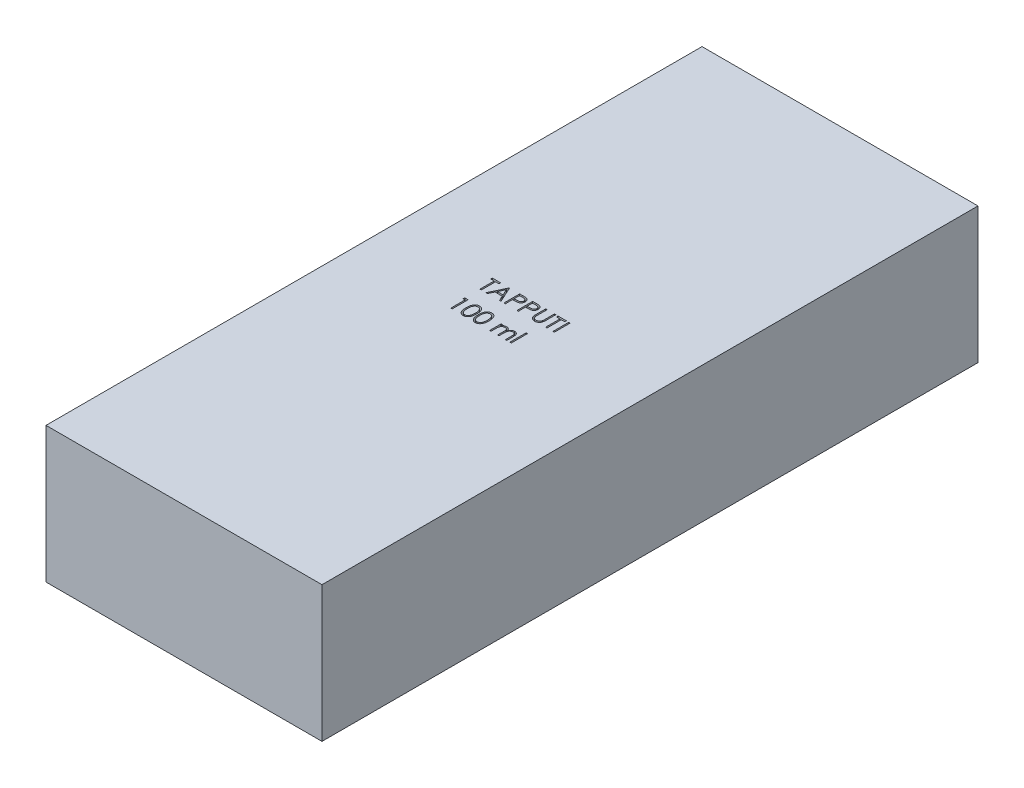
from build123d import *

# Parameters (mm, degrees)
SKETCH1_W           = 61
SKETCH1_H           = 145
BOSS_EXTRUDE1_DEPTH = 30
SKETCH2_W           = 0.314102564
SKETCH2_H           = 3.5
SKETCH2_H_2         = 3.58974359
CUT_EXTRUDE1_DEPTH  = 10


with BuildPart() as part:
    # Sketch1 → Boss-Extrude1 (new body)
    with BuildSketch(Plane(origin=(0, 0, 0), x_dir=(1, 0, 0), z_dir=(0, 1, 0))):
        Rectangle(SKETCH1_W, SKETCH1_H)
    extrude(amount=-BOSS_EXTRUDE1_DEPTH)

    # Sketch2 → Cut-Extrude1 (cut)
    with BuildSketch(Plane(origin=(0, 0, 0), x_dir=(1, 0, 0), z_dir=(0, 1, 0))):
        Polygon((-9.37530333, 4.660408726), (-9.37530333, 5.019383085), (-7.53555974, 5.019383085), (-7.53555974, 4.660408726), (-8.298380253, 4.660408726), (-8.298380253, 1.519383085), (-8.612482817, 1.519383085), (-8.612482817, 4.660408726), align=None)
        Polygon((-5.561200766, 5.019383085), (-3.94581615, 1.519383085), (-4.287262464, 1.519383085), (-4.804690349, 2.641177956), (-6.391328971, 2.641177956), (-6.923480413, 1.519383085), (-7.266328971, 1.519383085), (-5.60607256, 5.019383085), align=None)
        Polygon((-5.587142272, 4.337191578), (-6.220956374, 3.000152315), (-4.970155092, 3.000152315), align=None, mode=Mode.SUBTRACT)
        with BuildLine():
            Line((-3.317611022, 5.019383085), (-2.631212785, 5.019383085))
            add(Edge.make_bspline(
                [(-2.631212785, 5.019383085), (-2.584001879, 5.019331188), (-2.493543686, 5.019231753), (-2.36382863, 5.016217007), (-2.246018898, 5.012190315), (-2.140368518, 5.006608422), (-2.046552419, 5.000011831), (-1.96499512, 4.990759792), (-1.895055564, 4.981099497), (-1.853149114, 4.97127809), (-1.834037304, 4.96679895)],
                knots=[0, 0, 0, 0, 0.000141628, 0.000271366, 0.00038923, 0.000495248, 0.00058876, 0.000671296, 0.000741499, 0.00080036, 0.00080036, 0.00080036, 0.00080036], degree=3))
            add(Edge.make_bspline(
                [(-1.834037304, 4.96679895), (-1.80984377, 4.960177), (-1.762026793, 4.947089138), (-1.69312575, 4.920875415), (-1.627571904, 4.88979325), (-1.565140346, 4.85436931), (-1.506598263, 4.813083746), (-1.451072222, 4.767610128), (-1.399052242, 4.716898559), (-1.35083085, 4.66151782), (-1.306546052, 4.60239761), (-1.268416369, 4.53865538), (-1.236489142, 4.471364076), (-1.209105871, 4.400570505), (-1.189397416, 4.325680182), (-1.174550517, 4.247213469), (-1.165126889, 4.165178779), (-1.164224327, 4.109118912), (-1.163764868, 4.080581001)],
                knots=[0, 0, 0, 0, 7.5216e-05, 0.00014866, 0.000220794, 0.000292713, 0.000363707, 0.000435434, 0.000507823, 0.000581364, 0.000655543, 0.000729131, 0.000803767, 0.000878771, 0.000956497, 0.001035702, 0.001118238, 0.001203821, 0.001203821, 0.001203821, 0.001203821], degree=3))
            add(Edge.make_bspline(
                [(-1.163764868, 4.080581001), (-1.164186293, 4.051803224), (-1.165010839, 3.995497561), (-1.174907124, 3.913124772), (-1.188237316, 3.834406382), (-1.208734368, 3.759516932), (-1.235580041, 3.688901161), (-1.267072094, 3.621479929), (-1.305055624, 3.558400257), (-1.348700454, 3.49943314), (-1.397252048, 3.444523227), (-1.450504987, 3.394068433), (-1.508244279, 3.348364095), (-1.570286427, 3.307307751), (-1.637236276, 3.271851471), (-1.70807843, 3.240094166), (-1.783428646, 3.213423106), (-1.83557116, 3.199393044), (-1.862082176, 3.192259687)],
                knots=[0, 0, 0, 0, 8.6284e-05, 0.00016882, 0.000248587, 0.000325638, 0.000401297, 0.000474998, 0.000548586, 0.000621785, 0.0006948, 0.0007682, 0.000841564, 0.000915458, 0.000991056, 0.00106858, 0.00114819, 0.001230532, 0.001230532, 0.001230532, 0.001230532], degree=3))
            add(Edge.make_bspline(
                [(-1.862082176, 3.192259687), (-1.88400951, 3.187596706), (-1.932064537, 3.177377512), (-2.011207259, 3.165969055), (-2.103352645, 3.156231454), (-2.208374925, 3.148930317), (-2.32617983, 3.142679948), (-2.456831087, 3.137711854), (-2.600585165, 3.134982001), (-2.700856409, 3.134841208), (-2.753207977, 3.1347677)],
                knots=[0, 0, 0, 0, 6.7238e-05, 0.000147357, 0.000239727, 0.000345177, 0.000463135, 0.000593636, 0.000737393, 0.000894446, 0.000894446, 0.000894446, 0.000894446], degree=3))
            Line((-2.753207977, 3.1347677), (-3.003508458, 3.1347677))
            Line((-3.003508458, 3.1347677), (-3.003508458, 1.519383085))
            Line((-3.003508458, 1.519383085), (-3.317611022, 1.519383085))
            Line((-3.317611022, 1.519383085), (-3.317611022, 5.019383085))
        make_face()
        with BuildLine():
            Line((-3.003508458, 4.660408726), (-3.003508458, 3.493742059))
            Line((-3.003508458, 3.493742059), (-2.390728009, 3.486029719))
            add(Edge.make_bspline(
                [(-2.390728009, 3.486029719), (-2.360808083, 3.486014256), (-2.303048283, 3.485984403), (-2.21961206, 3.489969627), (-2.142202773, 3.49457016), (-2.071058197, 3.501306083), (-2.006146263, 3.510827341), (-1.947358734, 3.520439078), (-1.895151451, 3.534344441), (-1.834052249, 3.55306751), (-1.765968902, 3.585000126), (-1.691901353, 3.631350016), (-1.629130767, 3.690430724), (-1.57481247, 3.756858555), (-1.531706592, 3.830757685), (-1.5001506, 3.909826622), (-1.481609443, 3.993254471), (-1.479123249, 4.05034261), (-1.477867432, 4.079178758)],
                knots=[0, 0, 0, 0, 8.9746e-05, 0.000173253, 0.000250533, 0.00032239, 0.000387534, 0.00044736, 0.000500926, 0.000549486, 0.000638903, 0.000725641, 0.000810488, 0.000896226, 0.000982324, 0.00106604, 0.001150757, 0.001237226, 0.001237226, 0.001237226, 0.001237226], degree=3))
            add(Edge.make_bspline(
                [(-1.477867432, 4.079178758), (-1.479130079, 4.107317271), (-1.481640064, 4.163253153), (-1.500295927, 4.245231914), (-1.531645241, 4.323467618), (-1.575101835, 4.396440704), (-1.627842965, 4.462629508), (-1.689142308, 4.520126635), (-1.75885557, 4.566348337), (-1.823703801, 4.596181619), (-1.881304987, 4.614396894), (-1.931336947, 4.627141735), (-1.987827621, 4.637317341), (-2.050795401, 4.645556844), (-2.119752234, 4.652610305), (-2.195290549, 4.657396282), (-2.277124193, 4.660197739), (-2.333934763, 4.660336694), (-2.363384259, 4.660408726)],
                knots=[0, 0, 0, 0, 8.4371e-05, 0.000167719, 0.000250783, 0.000336277, 0.000421575, 0.000503926, 0.000587348, 0.000671427, 0.000717102, 0.000768457, 0.000826213, 0.000889178, 0.000958942, 0.001034123, 0.001116202, 0.001204546, 0.001204546, 0.001204546, 0.001204546], degree=3))
            Line((-2.363384259, 4.660408726), (-3.003508458, 4.660408726))
        make_face(mode=Mode.SUBTRACT)
        with BuildLine():
            Line((-0.44581615, 5.019383085), (0.240582087, 5.019383085))
            add(Edge.make_bspline(
                [(0.240582087, 5.019383085), (0.287792993, 5.019331188), (0.378251186, 5.019231753), (0.507966242, 5.016217007), (0.625775973, 5.012190315), (0.731426354, 5.006608422), (0.825242452, 5.000011831), (0.906799752, 4.990759792), (0.976739308, 4.981099497), (1.018645758, 4.97127809), (1.037757568, 4.96679895)],
                knots=[0, 0, 0, 0, 0.000141628, 0.000271366, 0.00038923, 0.000495248, 0.00058876, 0.000671296, 0.000741499, 0.00080036, 0.00080036, 0.00080036, 0.00080036], degree=3))
            add(Edge.make_bspline(
                [(1.037757568, 4.96679895), (1.061951102, 4.960177), (1.109768079, 4.947089138), (1.178669122, 4.920875415), (1.244222967, 4.88979325), (1.306654526, 4.85436931), (1.365196609, 4.813083746), (1.42072265, 4.767610128), (1.47274263, 4.716898559), (1.520964022, 4.66151782), (1.56524882, 4.60239761), (1.603378502, 4.53865538), (1.635305729, 4.471364076), (1.662689001, 4.400570505), (1.682397455, 4.325680182), (1.697244355, 4.247213469), (1.706667983, 4.165178779), (1.707570544, 4.109118912), (1.708030004, 4.080581001)],
                knots=[0, 0, 0, 0, 7.5216e-05, 0.00014866, 0.000220794, 0.000292713, 0.000363707, 0.000435434, 0.000507823, 0.000581364, 0.000655543, 0.000729131, 0.000803767, 0.000878771, 0.000956497, 0.001035702, 0.001118238, 0.001203821, 0.001203821, 0.001203821, 0.001203821], degree=3))
            add(Edge.make_bspline(
                [(1.708030004, 4.080581001), (1.707608579, 4.051803224), (1.706784033, 3.995497561), (1.696887748, 3.913124772), (1.683557556, 3.834406382), (1.663060504, 3.759516932), (1.636214831, 3.688901161), (1.604722778, 3.621479929), (1.566739247, 3.558400257), (1.523094418, 3.49943314), (1.474542823, 3.444523227), (1.421289885, 3.394068433), (1.363550593, 3.348364095), (1.301508445, 3.307307751), (1.234558596, 3.271851471), (1.163716442, 3.240094166), (1.088366226, 3.213423106), (1.036223712, 3.199393044), (1.009712696, 3.192259687)],
                knots=[0, 0, 0, 0, 8.6284e-05, 0.00016882, 0.000248587, 0.000325638, 0.000401297, 0.000474998, 0.000548586, 0.000621785, 0.0006948, 0.0007682, 0.000841564, 0.000915458, 0.000991056, 0.00106858, 0.00114819, 0.001230532, 0.001230532, 0.001230532, 0.001230532], degree=3))
            add(Edge.make_bspline(
                [(1.009712696, 3.192259687), (0.987785362, 3.187596706), (0.939730335, 3.177377512), (0.860587612, 3.165969055), (0.768442227, 3.156231454), (0.663419947, 3.148930317), (0.545615042, 3.142679948), (0.414963784, 3.137711854), (0.271209707, 3.134982001), (0.170938463, 3.134841208), (0.118586895, 3.1347677)],
                knots=[0, 0, 0, 0, 6.7238e-05, 0.000147357, 0.000239727, 0.000345177, 0.000463135, 0.000593636, 0.000737393, 0.000894446, 0.000894446, 0.000894446, 0.000894446], degree=3))
            Line((0.118586895, 3.1347677), (-0.131713586, 3.1347677))
            Line((-0.131713586, 3.1347677), (-0.131713586, 1.519383085))
            Line((-0.131713586, 1.519383085), (-0.44581615, 1.519383085))
            Line((-0.44581615, 1.519383085), (-0.44581615, 5.019383085))
        make_face()
        with BuildLine():
            Line((-0.131713586, 4.660408726), (-0.131713586, 3.493742059))
            Line((-0.131713586, 3.493742059), (0.481066863, 3.486029719))
            add(Edge.make_bspline(
                [(0.481066863, 3.486029719), (0.510986789, 3.486014256), (0.568746588, 3.485984403), (0.652182812, 3.489969627), (0.729592099, 3.49457016), (0.800736674, 3.501306083), (0.865648609, 3.510827341), (0.924436138, 3.520439078), (0.976643421, 3.534344441), (1.037742622, 3.55306751), (1.10582597, 3.585000126), (1.179893518, 3.631350016), (1.242664105, 3.690430724), (1.296982401, 3.756858555), (1.340088279, 3.830757685), (1.371644272, 3.909826622), (1.390185429, 3.993254471), (1.392671623, 4.05034261), (1.39392744, 4.079178758)],
                knots=[0, 0, 0, 0, 8.9746e-05, 0.000173253, 0.000250533, 0.00032239, 0.000387534, 0.00044736, 0.000500926, 0.000549486, 0.000638903, 0.000725641, 0.000810488, 0.000896226, 0.000982324, 0.00106604, 0.001150757, 0.001237226, 0.001237226, 0.001237226, 0.001237226], degree=3))
            add(Edge.make_bspline(
                [(1.39392744, 4.079178758), (1.392664793, 4.107317271), (1.390154808, 4.163253153), (1.371498945, 4.245231914), (1.340149631, 4.323467618), (1.296693037, 4.396440704), (1.243951907, 4.462629508), (1.182652564, 4.520126635), (1.112939302, 4.566348337), (1.048091071, 4.596181619), (0.990489885, 4.614396894), (0.940457925, 4.627141735), (0.883967251, 4.637317341), (0.820999471, 4.645556844), (0.752042637, 4.652610305), (0.676504322, 4.657396282), (0.594670679, 4.660197739), (0.537860108, 4.660336694), (0.508410613, 4.660408726)],
                knots=[0, 0, 0, 0, 8.4371e-05, 0.000167719, 0.000250783, 0.000336277, 0.000421575, 0.000503926, 0.000587348, 0.000671427, 0.000717102, 0.000768457, 0.000826213, 0.000889178, 0.000958942, 0.001034123, 0.001116202, 0.001204546, 0.001204546, 0.001204546, 0.001204546], degree=3))
            Line((0.508410613, 4.660408726), (-0.131713586, 4.660408726))
        make_face(mode=Mode.SUBTRACT)
        with BuildLine():
            Line((2.425978722, 5.019383085), (2.740081286, 5.019383085))
            Line((2.740081286, 5.019383085), (2.740081286, 2.922327796))
            add(Edge.make_bspline(
                [(2.740081286, 2.922327796), (2.740034542, 2.89264706), (2.739945837, 2.836322749), (2.740538351, 2.756154449), (2.742197719, 2.68488199), (2.743243879, 2.622230642), (2.745571212, 2.568487895), (2.747469259, 2.523362584), (2.749909816, 2.487068382), (2.752842934, 2.465887456), (2.754103722, 2.456782924)],
                knots=[0, 0, 0, 0, 8.9042e-05, 0.000168973, 0.000240502, 0.000302917, 0.000356945, 0.000401866, 0.000438432, 0.000465999, 0.000465999, 0.000465999, 0.000465999], degree=3))
            add(Edge.make_bspline(
                [(2.754103722, 2.456782924), (2.75928118, 2.423936161), (2.769344367, 2.360093432), (2.794990745, 2.26918515), (2.830808246, 2.187253692), (2.873251288, 2.111742401), (2.9291839, 2.044753041), (2.996187435, 1.983041388), (3.077365203, 1.929069583), (3.167625809, 1.879718771), (3.264911047, 1.840053689), (3.364322313, 1.810060325), (3.464365292, 1.791781425), (3.531341457, 1.789664886), (3.564600517, 1.788613854)],
                knots=[0, 0, 0, 0, 9.971e-05, 0.000193801, 0.000282365, 0.000367504, 0.000452699, 0.000543015, 0.000639862, 0.000744331, 0.000851226, 0.000954377, 0.001055468, 0.001155185, 0.001155185, 0.001155185, 0.001155185], degree=3))
            add(Edge.make_bspline(
                [(3.564600517, 1.788613854), (3.593154257, 1.789687704), (3.650096819, 1.791829202), (3.73470325, 1.805090633), (3.817103358, 1.828991199), (3.897704038, 1.859830958), (3.973255022, 1.900578549), (4.043798465, 1.947649388), (4.106762399, 2.002860264), (4.164220397, 2.063960609), (4.214255332, 2.132900409), (4.257626474, 2.208178547), (4.293152404, 2.290927894), (4.310695929, 2.349082316), (4.31970869, 2.378958405)],
                knots=[0, 0, 0, 0, 8.5678e-05, 0.00017086, 0.000256092, 0.000342674, 0.000429242, 0.000513055, 0.000596556, 0.000679898, 0.000764179, 0.00085149, 0.000940054, 0.001033621, 0.001033621, 0.001033621, 0.001033621], degree=3))
            add(Edge.make_bspline(
                [(4.31970869, 2.378958405), (4.322708815, 2.391306979), (4.329394303, 2.41882458), (4.335641348, 2.46534587), (4.342147874, 2.520235234), (4.346662444, 2.583887047), (4.351063664, 2.656088019), (4.353696737, 2.737214277), (4.35491377, 2.826971238), (4.35527645, 2.8896084), (4.355465901, 2.922327796)],
                knots=[0, 0, 0, 0, 3.81e-05, 8.4902e-05, 0.000140649, 0.000203941, 0.000276279, 0.000357657, 0.000447412, 0.000545571, 0.000545571, 0.000545571, 0.000545571], degree=3))
            Line((4.355465901, 2.922327796), (4.355465901, 5.019383085))
            Line((4.355465901, 5.019383085), (4.669568465, 5.019383085))
            Line((4.669568465, 5.019383085), (4.669568465, 2.905500873))
            add(Edge.make_bspline(
                [(4.669568465, 2.905500873), (4.669314345, 2.867402494), (4.668818413, 2.793051191), (4.664517837, 2.684099832), (4.657660837, 2.580746851), (4.647972749, 2.482978354), (4.635135746, 2.391144195), (4.620860525, 2.304439427), (4.602680992, 2.223486434), (4.581447591, 2.147654017), (4.557174043, 2.075468503), (4.525732895, 2.006959889), (4.490308395, 1.940045489), (4.448293742, 1.87573738), (4.401082359, 1.813750827), (4.347630679, 1.754461752), (4.289706518, 1.696922706), (4.226346958, 1.642609639), (4.158596433, 1.592800963), (4.086656475, 1.549003192), (4.011079705, 1.511979574), (3.932062579, 1.48150365), (3.849571376, 1.45858905), (3.763604017, 1.441513895), (3.673964823, 1.431811597), (3.613000167, 1.430369667), (3.582128561, 1.429639495)],
                knots=[0, 0, 0, 0, 0.000114291, 0.000223047, 0.000327049, 0.000424998, 0.000517708, 0.000605194, 0.000688542, 0.000766455, 0.0008414, 0.000916717, 0.000992315, 0.001068354, 0.001146882, 0.001225836, 0.001307639, 0.001391671, 0.001475952, 0.001559641, 0.001643989, 0.001728103, 0.001813335, 0.001900511, 0.00199079, 0.002083404, 0.002083404, 0.002083404, 0.002083404], degree=3))
            add(Edge.make_bspline(
                [(3.582128561, 1.429639495), (3.548459459, 1.43042426), (3.4824008, 1.431963967), (3.385062733, 1.440786717), (3.291748536, 1.457405111), (3.201472659, 1.478565055), (3.115464162, 1.507748792), (3.032570718, 1.541846917), (2.954212037, 1.583724177), (2.879116908, 1.63031757), (2.809292152, 1.682742209), (2.745194749, 1.739882382), (2.686718878, 1.80082276), (2.634850182, 1.866223126), (2.588729297, 1.935574833), (2.548999084, 2.009074072), (2.51488584, 2.086692389), (2.497279273, 2.140645589), (2.488378561, 2.167920745)],
                knots=[0, 0, 0, 0, 0.000101022, 0.000198206, 0.000292839, 0.000385177, 0.00047608, 0.000565014, 0.000653769, 0.000742283, 0.000829923, 0.000915339, 0.000999643, 0.001082971, 0.00116542, 0.001249186, 0.001333332, 0.001419362, 0.001419362, 0.001419362, 0.001419362], degree=3))
            add(Edge.make_bspline(
                [(2.488378561, 2.167920745), (2.483201403, 2.186553319), (2.471972032, 2.226967788), (2.459946734, 2.293854277), (2.449837653, 2.370869194), (2.440332094, 2.458017813), (2.434723136, 2.555367679), (2.429805698, 2.662876595), (2.425944079, 2.780674557), (2.425966851, 2.862729073), (2.425978722, 2.905500873)],
                knots=[0, 0, 0, 0, 5.799e-05, 0.000125782, 0.000203619, 0.000291034, 0.000388694, 0.000496078, 0.000613919, 0.000742226, 0.000742226, 0.000742226, 0.000742226], degree=3))
            Line((2.425978722, 2.905500873), (2.425978722, 5.019383085))
        make_face()
        Polygon((5.163158209, 4.660408726), (5.163158209, 5.019383085), (7.002901799, 5.019383085), (7.002901799, 4.660408726), (6.240081286, 4.660408726), (6.240081286, 1.519383085), (5.925978722, 1.519383085), (5.925978722, 4.660408726), align=None)
        with Locations((7.698414619, 3.269383085)):
            Rectangle(SKETCH2_W, SKETCH2_H)
        Polygon((-8.541669516, -1.813950249), (-7.894534099, -1.813950249), (-7.894534099, -5.313950249), (-8.208636663, -5.313950249), (-8.208636663, -2.172924608), (-8.747098201, -2.172924608), align=None)
        with BuildLine():
            add(Edge.make_bspline(
                [(-6.593252048, -3.565352492), (-6.592924029, -3.509255105), (-6.592286849, -3.40028512), (-6.585198428, -3.241500478), (-6.573423086, -3.092540189), (-6.557285713, -2.953397123), (-6.537647733, -2.824035359), (-6.511432246, -2.704800602), (-6.481619444, -2.595140995), (-6.447066998, -2.494698947), (-6.408079209, -2.402121243), (-6.365644948, -2.315696042), (-6.318080154, -2.23555411), (-6.268103241, -2.160416319), (-6.213691169, -2.091512625), (-6.156392379, -2.027869962), (-6.093970503, -1.970959212), (-6.028547494, -1.919112909), (-5.95953103, -1.873663438), (-5.888888364, -1.833630699), (-5.816133258, -1.799430832), (-5.741067075, -1.772540396), (-5.664364517, -1.750329549), (-5.58575745, -1.735140601), (-5.505116087, -1.725583693), (-5.450684652, -1.724670025), (-5.423079772, -1.724206659)],
                knots=[0, 0, 0, 0, 0.000168282, 0.000326891, 0.000476705, 0.00061646, 0.000747059, 0.00086904, 0.000982494, 0.001087814, 0.001187428, 0.001283689, 0.001376399, 0.001466822, 0.001554203, 0.001639568, 0.001723424, 0.001807301, 0.001889751, 0.001971063, 0.002050735, 0.002130583, 0.002210036, 0.002290062, 0.002370508, 0.002453288, 0.002453288, 0.002453288, 0.002453288], degree=3))
            add(Edge.make_bspline(
                [(-5.423079772, -1.724206659), (-5.395244293, -1.724694474), (-5.339888285, -1.725664585), (-5.258047909, -1.734988528), (-5.178098228, -1.750459651), (-5.100380089, -1.772380625), (-5.024255102, -1.799576302), (-4.950318695, -1.833663419), (-4.878111613, -1.873342286), (-4.808781326, -1.919966164), (-4.74156671, -1.97194844), (-4.678118747, -2.030711109), (-4.618431661, -2.095660828), (-4.561756356, -2.166102692), (-4.509700759, -2.243387777), (-4.460127327, -2.326171887), (-4.415755291, -2.415902751), (-4.373020615, -2.511083219), (-4.336133629, -2.614346878), (-4.302867383, -2.725111638), (-4.275988415, -2.844685825), (-4.253599143, -2.972442071), (-4.236254247, -3.108849554), (-4.223621605, -3.253615869), (-4.21694852, -3.40683626), (-4.215691818, -3.511594109), (-4.215046919, -3.565352492)],
                knots=[0, 0, 0, 0, 8.3481e-05, 0.000166017, 0.000246731, 0.000327534, 0.000408041, 0.000488986, 0.000571522, 0.000654944, 0.000739373, 0.000826202, 0.000914021, 0.001003809, 0.001097153, 0.001193347, 0.001293057, 0.001397277, 0.001506176, 0.001621751, 0.001744038, 0.001873599, 0.002010742, 0.002156422, 0.002309427, 0.002470709, 0.002470709, 0.002470709, 0.002470709], degree=3))
            add(Edge.make_bspline(
                [(-4.215046919, -3.565352492), (-4.215698504, -3.6188764), (-4.21696809, -3.723165552), (-4.223546797, -3.875696527), (-4.236505428, -4.019694571), (-4.252715416, -4.155505033), (-4.275166379, -4.282562652), (-4.302771545, -4.401307101), (-4.333421868, -4.512251172), (-4.371256662, -4.614485984), (-4.412667373, -4.709437707), (-4.457722569, -4.798104855), (-4.505992395, -4.881271148), (-4.55858114, -4.958270895), (-4.614634553, -5.029649552), (-4.675352342, -5.094147174), (-4.739022927, -5.153317846), (-4.806435343, -5.205969474), (-4.876846894, -5.252054278), (-4.948805971, -5.293268129), (-5.023589354, -5.326500824), (-5.099502307, -5.355035865), (-5.177630673, -5.376836317), (-5.257877064, -5.391910172), (-5.3398333, -5.402482021), (-5.395234865, -5.403288501), (-5.423079772, -5.403693838)],
                knots=[0, 0, 0, 0, 0.000160581, 0.000312886, 0.000457868, 0.000594226, 0.000723097, 0.000844701, 0.000959884, 0.001068125, 0.001171421, 0.001270505, 0.001366343, 0.001459687, 0.001550023, 0.00163832, 0.001725149, 0.001810562, 0.001894568, 0.001977446, 0.00205903, 0.002139777, 0.00222058, 0.002301983, 0.002384599, 0.00246808, 0.00246808, 0.00246808, 0.00246808], degree=3))
            add(Edge.make_bspline(
                [(-5.423079772, -5.403693838), (-5.450683886, -5.403227483), (-5.505113811, -5.402307921), (-5.585766236, -5.39279419), (-5.66404868, -5.377498686), (-5.740347434, -5.356082082), (-5.815053949, -5.329867246), (-5.887150235, -5.295713562), (-5.957437919, -5.256379493), (-6.025729475, -5.211584072), (-6.090741636, -5.160262389), (-6.152840241, -5.1034981), (-6.21046526, -5.039874689), (-6.264099356, -4.970396766), (-6.315073444, -4.895703523), (-6.361962818, -4.81477515), (-6.405333672, -4.72793254), (-6.444977162, -4.634614629), (-6.480125826, -4.533459701), (-6.511173534, -4.423310523), (-6.535687691, -4.303194887), (-6.556670647, -4.17407752), (-6.57359503, -4.035403589), (-6.585149355, -3.887097811), (-6.59229067, -3.729252602), (-6.592925741, -3.620982828), (-6.593252048, -3.565352492)],
                knots=[0, 0, 0, 0, 8.278e-05, 0.000163226, 0.000243252, 0.00032184, 0.00040079, 0.000480463, 0.00056082, 0.000642298, 0.000725191, 0.000809047, 0.000894412, 0.000982346, 0.001072188, 0.001165503, 0.001262704, 0.001363236, 0.001469448, 0.001583766, 0.001706286, 0.001836995, 0.001976138, 0.002125253, 0.002283161, 0.002450041, 0.002450041, 0.002450041, 0.002450041], degree=3))
        make_face()
        with BuildLine():
            add(Edge.make_bspline(
                [(-6.279149483, -3.563950249), (-6.279030036, -3.610698948), (-6.278798213, -3.701428992), (-6.272742013, -3.833272253), (-6.264491781, -3.956242582), (-6.253850483, -4.070496119), (-6.238047535, -4.175646131), (-6.220340747, -4.272415814), (-6.198792657, -4.360293051), (-6.17329764, -4.439880862), (-6.144258543, -4.51252993), (-6.112552679, -4.580131146), (-6.078491956, -4.643483082), (-6.040372805, -4.70201669), (-5.998857742, -4.755922854), (-5.954884483, -4.806155687), (-5.906811899, -4.850952668), (-5.840308156, -4.904679523), (-5.752511682, -4.960198657), (-5.641891227, -5.008544747), (-5.528222776, -5.038927203), (-5.451071526, -5.042790959), (-5.412562945, -5.04471948)],
                knots=[0, 0, 0, 0, 0.000140231, 0.000272162, 0.000395845, 0.00050998, 0.000616273, 0.00071473, 0.000805025, 0.000887508, 0.000965234, 0.00103957, 0.001111417, 0.001180842, 0.001248855, 0.001315406, 0.001380877, 0.0014457, 0.001571746, 0.00169106, 0.001806864, 0.001922266, 0.001922266, 0.001922266, 0.001922266], degree=3))
            add(Edge.make_bspline(
                [(-5.412562945, -5.04471948), (-5.373805273, -5.043121699), (-5.29636995, -5.039929436), (-5.183236155, -5.009130699), (-5.073405885, -4.962661159), (-4.987333945, -4.907713654), (-4.921851401, -4.855385324), (-4.874934411, -4.810770676), (-4.831872363, -4.760814809), (-4.791030288, -4.706915513), (-4.753571212, -4.648043028), (-4.719508074, -4.584480453), (-4.688424727, -4.516051275), (-4.670715681, -4.468281536), (-4.661661503, -4.443858101)],
                knots=[0, 0, 0, 0, 0.000116044, 0.000231848, 0.000349318, 0.000472837, 0.000536674, 0.000600645, 0.000666733, 0.000734322, 0.000803367, 0.000875831, 0.000950509, 0.001028633, 0.001028633, 0.001028633, 0.001028633], degree=3))
            add(Edge.make_bspline(
                [(-4.661661503, -4.443858101), (-4.651109735, -4.412628362), (-4.629685121, -4.349218598), (-4.602073347, -4.250854946), (-4.580327948, -4.147652182), (-4.560764582, -4.040227065), (-4.547411526, -3.927787364), (-4.536663713, -3.81068098), (-4.530333026, -3.688819618), (-4.529548275, -3.606024626), (-4.529149483, -3.563950249)],
                knots=[0, 0, 0, 0, 9.8886e-05, 0.00020078, 0.000306259, 0.000415188, 0.00052824, 0.000645799, 0.000767957, 0.000894177, 0.000894177, 0.000894177, 0.000894177], degree=3))
            add(Edge.make_bspline(
                [(-4.529149483, -3.563950249), (-4.529699673, -3.521882676), (-4.53077596, -3.439589511), (-4.534889948, -3.319071331), (-4.545513523, -3.20460357), (-4.557312642, -3.095693097), (-4.574709863, -2.992942794), (-4.593467669, -2.895492489), (-4.618668882, -2.804549464), (-4.645588657, -2.718689883), (-4.676399052, -2.638889228), (-4.710314787, -2.564775442), (-4.746536545, -2.495990717), (-4.785878786, -2.432723776), (-4.827874469, -2.374691233), (-4.873632018, -2.323056638), (-4.921336391, -2.27621967), (-4.988153577, -2.222757101), (-5.075627866, -2.168245405), (-5.184473514, -2.118079645), (-5.297744158, -2.089271353), (-5.374317612, -2.085209666), (-5.412562945, -2.083181018)],
                knots=[0, 0, 0, 0, 0.000126219, 0.000246912, 0.000361616, 0.00047102, 0.00057545, 0.000674176, 0.000768567, 0.000858368, 0.000944043, 0.001024988, 0.001102772, 0.001177091, 0.00124833, 0.001317386, 0.001383826, 0.001448649, 0.001573728, 0.001692043, 0.001806995, 0.001921698, 0.001921698, 0.001921698, 0.001921698], degree=3))
            add(Edge.make_bspline(
                [(-5.412562945, -2.083181018), (-5.451273537, -2.085212465), (-5.528765243, -2.089279059), (-5.643213197, -2.117972312), (-5.752917549, -2.167985278), (-5.840160524, -2.222937651), (-5.90702431, -2.275275962), (-5.954107004, -2.320662416), (-5.998253176, -2.370308671), (-6.038920876, -2.424710585), (-6.077010159, -2.483175953), (-6.111991172, -2.546164717), (-6.143508501, -2.613996082), (-6.172593038, -2.686612517), (-6.198165826, -2.766193462), (-6.219259789, -2.853962455), (-6.238746842, -2.950424347), (-6.252542111, -3.056143855), (-6.264805867, -3.170426008), (-6.272687215, -3.293703326), (-6.278818472, -3.425767707), (-6.279036936, -3.516966865), (-6.279149483, -3.563950249)],
                knots=[0, 0, 0, 0, 0.000116101, 0.000232413, 0.000351368, 0.000476447, 0.000540832, 0.000605795, 0.000672346, 0.000739935, 0.00080936, 0.000881545, 0.00095588, 0.001033607, 0.001116089, 0.001206384, 0.001304286, 0.001411174, 0.001526077, 0.001649061, 0.001781692, 0.001922624, 0.001922624, 0.001922624, 0.001922624], degree=3))
        make_face(mode=Mode.SUBTRACT)
        with BuildLine():
            add(Edge.make_bspline(
                [(-3.900944355, -3.565352492), (-3.900616337, -3.509255105), (-3.899979157, -3.40028512), (-3.892890736, -3.241500478), (-3.881115394, -3.092540189), (-3.864978021, -2.953397123), (-3.845340041, -2.824035359), (-3.819124554, -2.704800602), (-3.789311752, -2.595140995), (-3.754759306, -2.494698947), (-3.715771517, -2.402121243), (-3.673337256, -2.315696042), (-3.625772462, -2.23555411), (-3.575795549, -2.160416319), (-3.521383477, -2.091512625), (-3.464084687, -2.027869962), (-3.40166281, -1.970959212), (-3.336239802, -1.919112909), (-3.267223338, -1.873663438), (-3.196580671, -1.833630699), (-3.123825566, -1.799430832), (-3.048759383, -1.772540396), (-2.972056825, -1.750329549), (-2.893449758, -1.735140601), (-2.812808394, -1.725583693), (-2.758376959, -1.724670025), (-2.73077208, -1.724206659)],
                knots=[0, 0, 0, 0, 0.000168282, 0.000326891, 0.000476705, 0.00061646, 0.000747059, 0.00086904, 0.000982494, 0.001087814, 0.001187428, 0.001283689, 0.001376399, 0.001466822, 0.001554203, 0.001639568, 0.001723424, 0.001807301, 0.001889751, 0.001971063, 0.002050735, 0.002130583, 0.002210036, 0.002290062, 0.002370508, 0.002453288, 0.002453288, 0.002453288, 0.002453288], degree=3))
            add(Edge.make_bspline(
                [(-2.73077208, -1.724206659), (-2.702936601, -1.724694474), (-2.647580592, -1.725664585), (-2.565740217, -1.734988528), (-2.485790535, -1.750459651), (-2.408072397, -1.772380625), (-2.33194741, -1.799576302), (-2.258011002, -1.833663419), (-2.185803921, -1.873342286), (-2.116473633, -1.919966164), (-2.049259018, -1.97194844), (-1.985811055, -2.030711109), (-1.926123969, -2.095660828), (-1.869448664, -2.166102692), (-1.817393066, -2.243387777), (-1.767819634, -2.326171887), (-1.723447598, -2.415902751), (-1.680712923, -2.511083219), (-1.643825936, -2.614346878), (-1.610559691, -2.725111638), (-1.583680723, -2.844685825), (-1.56129145, -2.972442071), (-1.543946554, -3.108849554), (-1.531313912, -3.253615869), (-1.524640827, -3.40683626), (-1.523384126, -3.511594109), (-1.522739227, -3.565352492)],
                knots=[0, 0, 0, 0, 8.3481e-05, 0.000166017, 0.000246731, 0.000327534, 0.000408041, 0.000488986, 0.000571522, 0.000654944, 0.000739373, 0.000826202, 0.000914021, 0.001003809, 0.001097153, 0.001193347, 0.001293057, 0.001397277, 0.001506176, 0.001621751, 0.001744038, 0.001873599, 0.002010742, 0.002156422, 0.002309427, 0.002470709, 0.002470709, 0.002470709, 0.002470709], degree=3))
            add(Edge.make_bspline(
                [(-1.522739227, -3.565352492), (-1.523390812, -3.6188764), (-1.524660398, -3.723165552), (-1.531239104, -3.875696527), (-1.544197735, -4.019694571), (-1.560407724, -4.155505033), (-1.582858687, -4.282562652), (-1.610463853, -4.401307101), (-1.641114176, -4.512251172), (-1.67894897, -4.614485984), (-1.72035968, -4.709437707), (-1.765414876, -4.798104855), (-1.813684703, -4.881271148), (-1.866273448, -4.958270895), (-1.922326861, -5.029649552), (-1.98304465, -5.094147174), (-2.046715235, -5.153317846), (-2.11412765, -5.205969474), (-2.184539202, -5.252054278), (-2.256498279, -5.293268129), (-2.331281662, -5.326500824), (-2.407194615, -5.355035865), (-2.485322981, -5.376836317), (-2.565569371, -5.391910172), (-2.647525607, -5.402482021), (-2.702927173, -5.403288501), (-2.73077208, -5.403693838)],
                knots=[0, 0, 0, 0, 0.000160581, 0.000312886, 0.000457868, 0.000594226, 0.000723097, 0.000844701, 0.000959884, 0.001068125, 0.001171421, 0.001270505, 0.001366343, 0.001459687, 0.001550023, 0.00163832, 0.001725149, 0.001810562, 0.001894568, 0.001977446, 0.00205903, 0.002139777, 0.00222058, 0.002301983, 0.002384599, 0.00246808, 0.00246808, 0.00246808, 0.00246808], degree=3))
            add(Edge.make_bspline(
                [(-2.73077208, -5.403693838), (-2.758376194, -5.403227483), (-2.812806118, -5.402307921), (-2.893458544, -5.39279419), (-2.971740987, -5.377498686), (-3.048039741, -5.356082082), (-3.122746256, -5.329867246), (-3.194842543, -5.295713562), (-3.265130227, -5.256379493), (-3.333421783, -5.211584072), (-3.398433944, -5.160262389), (-3.460532549, -5.1034981), (-3.518157568, -5.039874689), (-3.571791664, -4.970396766), (-3.622765752, -4.895703523), (-3.669655125, -4.81477515), (-3.713025979, -4.72793254), (-3.75266947, -4.634614629), (-3.787818134, -4.533459701), (-3.818865842, -4.423310523), (-3.843379999, -4.303194887), (-3.864362954, -4.17407752), (-3.881287338, -4.035403589), (-3.892841663, -3.887097811), (-3.899982978, -3.729252602), (-3.900618048, -3.620982828), (-3.900944355, -3.565352492)],
                knots=[0, 0, 0, 0, 8.278e-05, 0.000163226, 0.000243252, 0.00032184, 0.00040079, 0.000480463, 0.00056082, 0.000642298, 0.000725191, 0.000809047, 0.000894412, 0.000982346, 0.001072188, 0.001165503, 0.001262704, 0.001363236, 0.001469448, 0.001583766, 0.001706286, 0.001836995, 0.001976138, 0.002125253, 0.002283161, 0.002450041, 0.002450041, 0.002450041, 0.002450041], degree=3))
        make_face()
        with BuildLine():
            add(Edge.make_bspline(
                [(-3.586841791, -3.563950249), (-3.586722344, -3.610698948), (-3.586490521, -3.701428992), (-3.58043432, -3.833272253), (-3.572184088, -3.956242582), (-3.561542791, -4.070496119), (-3.545739842, -4.175646131), (-3.528033055, -4.272415814), (-3.506484965, -4.360293051), (-3.480989947, -4.439880862), (-3.45195085, -4.51252993), (-3.420244987, -4.580131146), (-3.386184264, -4.643483082), (-3.348065113, -4.70201669), (-3.30655005, -4.755922854), (-3.262576791, -4.806155687), (-3.214504207, -4.850952668), (-3.148000464, -4.904679523), (-3.06020399, -4.960198657), (-2.949583534, -5.008544747), (-2.835915083, -5.038927203), (-2.758763833, -5.042790959), (-2.720255253, -5.04471948)],
                knots=[0, 0, 0, 0, 0.000140231, 0.000272162, 0.000395845, 0.00050998, 0.000616273, 0.00071473, 0.000805025, 0.000887508, 0.000965234, 0.00103957, 0.001111417, 0.001180842, 0.001248855, 0.001315406, 0.001380877, 0.0014457, 0.001571746, 0.00169106, 0.001806864, 0.001922266, 0.001922266, 0.001922266, 0.001922266], degree=3))
            add(Edge.make_bspline(
                [(-2.720255253, -5.04471948), (-2.681497581, -5.043121699), (-2.604062258, -5.039929436), (-2.490928463, -5.009130699), (-2.381098193, -4.962661159), (-2.295026252, -4.907713654), (-2.229543709, -4.855385324), (-2.182626719, -4.810770676), (-2.13956467, -4.760814809), (-2.098722595, -4.706915513), (-2.06126352, -4.648043028), (-2.027200382, -4.584480453), (-1.996117035, -4.516051275), (-1.978407989, -4.468281536), (-1.96935381, -4.443858101)],
                knots=[0, 0, 0, 0, 0.000116044, 0.000231848, 0.000349318, 0.000472837, 0.000536674, 0.000600645, 0.000666733, 0.000734322, 0.000803367, 0.000875831, 0.000950509, 0.001028633, 0.001028633, 0.001028633, 0.001028633], degree=3))
            add(Edge.make_bspline(
                [(-1.96935381, -4.443858101), (-1.958802043, -4.412628362), (-1.937377429, -4.349218598), (-1.909765654, -4.250854946), (-1.888020255, -4.147652182), (-1.86845689, -4.040227065), (-1.855103834, -3.927787364), (-1.84435602, -3.81068098), (-1.838025333, -3.688819618), (-1.837240582, -3.606024626), (-1.836841791, -3.563950249)],
                knots=[0, 0, 0, 0, 9.8886e-05, 0.00020078, 0.000306259, 0.000415188, 0.00052824, 0.000645799, 0.000767957, 0.000894177, 0.000894177, 0.000894177, 0.000894177], degree=3))
            add(Edge.make_bspline(
                [(-1.836841791, -3.563950249), (-1.83739198, -3.521882676), (-1.838468268, -3.439589511), (-1.842582256, -3.319071331), (-1.85320583, -3.20460357), (-1.865004949, -3.095693097), (-1.88240217, -2.992942794), (-1.901159977, -2.895492489), (-1.926361189, -2.804549464), (-1.953280964, -2.718689883), (-1.98409136, -2.638889228), (-2.018007094, -2.564775442), (-2.054228853, -2.495990717), (-2.093571093, -2.432723776), (-2.135566777, -2.374691233), (-2.181324326, -2.323056638), (-2.229028699, -2.27621967), (-2.295845884, -2.222757101), (-2.383320174, -2.168245405), (-2.492165821, -2.118079645), (-2.605436466, -2.089271353), (-2.68200992, -2.085209666), (-2.720255253, -2.083181018)],
                knots=[0, 0, 0, 0, 0.000126219, 0.000246912, 0.000361616, 0.00047102, 0.00057545, 0.000674176, 0.000768567, 0.000858368, 0.000944043, 0.001024988, 0.001102772, 0.001177091, 0.00124833, 0.001317386, 0.001383826, 0.001448649, 0.001573728, 0.001692043, 0.001806995, 0.001921698, 0.001921698, 0.001921698, 0.001921698], degree=3))
            add(Edge.make_bspline(
                [(-2.720255253, -2.083181018), (-2.758965845, -2.085212465), (-2.83645755, -2.089279059), (-2.950905505, -2.117972312), (-3.060609857, -2.167985278), (-3.147852831, -2.222937651), (-3.214716618, -2.275275962), (-3.261799311, -2.320662416), (-3.305945484, -2.370308671), (-3.346613184, -2.424710585), (-3.384702467, -2.483175953), (-3.419683479, -2.546164717), (-3.451200809, -2.613996082), (-3.480285345, -2.686612517), (-3.505858133, -2.766193462), (-3.526952097, -2.853962455), (-3.54643915, -2.950424347), (-3.560234419, -3.056143855), (-3.572498174, -3.170426008), (-3.580379522, -3.293703326), (-3.58651078, -3.425767707), (-3.586729244, -3.516966865), (-3.586841791, -3.563950249)],
                knots=[0, 0, 0, 0, 0.000116101, 0.000232413, 0.000351368, 0.000476447, 0.000540832, 0.000605795, 0.000672346, 0.000739935, 0.00080936, 0.000881545, 0.00095588, 0.001033607, 0.001116089, 0.001206384, 0.001304286, 0.001411174, 0.001526077, 0.001649061, 0.001781692, 0.001922624, 0.001922624, 0.001922624, 0.001922624], degree=3))
        make_face(mode=Mode.SUBTRACT)
        with BuildLine():
            Line((0.361876158, -2.756257941), (0.675978722, -2.756257941))
            Line((0.675978722, -2.756257941), (0.675978722, -3.200769159))
            add(Edge.make_bspline(
                [(0.675978722, -3.200769159), (0.704262672, -3.161881557), (0.758457431, -3.087369184), (0.847323084, -2.9891789), (0.936099196, -2.905850745), (1.000032578, -2.862107874), (1.03074635, -2.841093678)],
                knots=[0, 0, 0, 0, 0.000144152, 0.000276209, 0.000396804, 0.000508302, 0.000508302, 0.000508302, 0.000508302], degree=3))
            add(Edge.make_bspline(
                [(1.03074635, -2.841093678), (1.072611012, -2.821088313), (1.155608912, -2.7814271), (1.287028137, -2.741193541), (1.421502806, -2.716468439), (1.51231102, -2.713087066), (1.55798994, -2.711386146)],
                knots=[0, 0, 0, 0, 0.000139031, 0.000275633, 0.000410962, 0.000547939, 0.000547939, 0.000547939, 0.000547939], degree=3))
            add(Edge.make_bspline(
                [(1.55798994, -2.711386146), (1.588882936, -2.712431437), (1.650018515, -2.714500011), (1.740602605, -2.727960046), (1.828461217, -2.751226219), (1.913075246, -2.783633543), (1.992795926, -2.82288023), (2.065885124, -2.868929938), (2.131509332, -2.920627014), (2.189635383, -2.980305947), (2.241904408, -3.049642545), (2.289983255, -3.130506794), (2.334408467, -3.224714455), (2.359029776, -3.293080996), (2.371992343, -3.329074447)],
                knots=[0, 0, 0, 0, 9.2678e-05, 0.000183405, 0.000274048, 0.000364807, 0.000454797, 0.00054019, 0.000623517, 0.000704829, 0.000789387, 0.000883415, 0.000986597, 0.001101318, 0.001101318, 0.001101318, 0.001101318], degree=3))
            add(Edge.make_bspline(
                [(2.371992343, -3.329074447), (2.385703595, -3.304350028), (2.412685412, -3.255695843), (2.457991049, -3.186837581), (2.505458845, -3.122430789), (2.555493339, -3.062424365), (2.607917925, -3.007114634), (2.662979326, -2.956318733), (2.720364107, -2.909818519), (2.800156347, -2.85549536), (2.903968954, -2.797794178), (3.034857069, -2.747765734), (3.171007241, -2.716849606), (3.263424939, -2.713219333), (3.310093305, -2.711386146)],
                knots=[0, 0, 0, 0, 8.4789e-05, 0.000166854, 0.000247064, 0.000324714, 0.000401089, 0.000475513, 0.000549314, 0.000622436, 0.0007649, 0.000904487, 0.001041601, 0.001181469, 0.001181469, 0.001181469, 0.001181469], degree=3))
            add(Edge.make_bspline(
                [(3.310093305, -2.711386146), (3.352974768, -2.713003367), (3.436897954, -2.716168425), (3.55907522, -2.741021899), (3.673017025, -2.783699546), (3.778494101, -2.841933182), (3.873653915, -2.915112366), (3.956370224, -3.002181203), (4.026140587, -3.102523826), (4.071719227, -3.196915815), (4.102634491, -3.280251148), (4.121695725, -3.351257439), (4.138535421, -3.429408992), (4.152516666, -3.514799254), (4.162735218, -3.607729862), (4.170305933, -3.708048738), (4.175430007, -3.815833849), (4.175792079, -3.89019935), (4.175978722, -3.928533582)],
                knots=[0, 0, 0, 0, 0.000128581, 0.000251645, 0.00037211, 0.000492305, 0.000611786, 0.000730807, 0.000851198, 0.000976936, 0.001044145, 0.001117629, 0.001197252, 0.00128393, 0.001377074, 0.001477631, 0.001585715, 0.001700707, 0.001700707, 0.001700707, 0.001700707], degree=3))
            Line((4.175978722, -3.928533582), (4.175978722, -5.313950249))
            Line((4.175978722, -5.313950249), (3.861876158, -5.313950249))
            Line((3.861876158, -5.313950249), (3.861876158, -3.927131338))
            add(Edge.make_bspline(
                [(3.861876158, -3.927131338), (3.861798275, -3.894410765), (3.861648595, -3.831526798), (3.858954964, -3.741274346), (3.85387965, -3.659005989), (3.847945011, -3.584833901), (3.839701202, -3.518585113), (3.82905527, -3.460392694), (3.81777759, -3.409798883), (3.799041599, -3.353712835), (3.769093707, -3.291842625), (3.723476227, -3.225119049), (3.666006121, -3.167038249), (3.599645964, -3.116619932), (3.52409752, -3.075626291), (3.440832797, -3.046350281), (3.350368745, -3.028227403), (3.287745956, -3.026421387), (3.255405805, -3.02548871)],
                knots=[0, 0, 0, 0, 9.816e-05, 0.000188648, 0.000270826, 0.000345412, 0.000411852, 0.000470988, 0.000522857, 0.0005672, 0.000648106, 0.000728233, 0.000808554, 0.000892128, 0.000977461, 0.001065278, 0.001156029, 0.001252946, 0.001252946, 0.001252946, 0.001252946], degree=3))
            add(Edge.make_bspline(
                [(3.255405805, -3.02548871), (3.215735851, -3.026904868), (3.137332939, -3.029703733), (3.022887453, -3.058277606), (2.912916437, -3.101357857), (2.810701304, -3.163790314), (2.716673513, -3.238598678), (2.635773935, -3.327548273), (2.56894175, -3.4281782), (2.523687774, -3.521324903), (2.495098472, -3.604994347), (2.476221557, -3.678091719), (2.461538165, -3.761173286), (2.447767636, -3.853680777), (2.438779908, -3.956250958), (2.430611536, -4.068409359), (2.426790673, -4.190493318), (2.426256214, -4.275120007), (2.425978722, -4.319058422)],
                knots=[0, 0, 0, 0, 0.000118788, 0.00023477, 0.000351815, 0.000471937, 0.000592603, 0.000711217, 0.000831002, 0.000953929, 0.001020668, 0.001096002, 0.00118016, 0.001273662, 0.001376495, 0.001488939, 0.001611007, 0.001742825, 0.001742825, 0.001742825, 0.001742825], degree=3))
            Line((2.425978722, -4.319058422), (2.425978722, -5.313950249))
            Line((2.425978722, -5.313950249), (2.111876158, -5.313950249))
            Line((2.111876158, -5.313950249), (2.111876158, -4.013369319))
            add(Edge.make_bspline(
                [(2.111876158, -4.013369319), (2.111796727, -3.976676), (2.111643909, -3.906081743), (2.108967592, -3.804848068), (2.10388097, -3.712766988), (2.098000422, -3.629945524), (2.089540243, -3.556534195), (2.079930481, -3.492139437), (2.068581871, -3.436922686), (2.049791986, -3.376359301), (2.021077518, -3.309638378), (1.974889256, -3.238497357), (1.917281676, -3.17622926), (1.8497108, -3.123070511), (1.773705118, -3.07912903), (1.689721717, -3.047469278), (1.598516804, -3.029044989), (1.535639098, -3.026696492), (1.50330244, -3.02548871)],
                knots=[0, 0, 0, 0, 0.000110078, 0.00021178, 0.000303758, 0.00038673, 0.000460827, 0.00052538, 0.000582037, 0.000629718, 0.00071543, 0.000799052, 0.000882908, 0.000968755, 0.001056067, 0.001145266, 0.001236843, 0.001333803, 0.001333803, 0.001333803, 0.001333803], degree=3))
            add(Edge.make_bspline(
                [(1.50330244, -3.02548871), (1.465286228, -3.02701917), (1.389521269, -3.030069323), (1.278219299, -3.057523597), (1.170733615, -3.100527671), (1.068778917, -3.16018749), (0.975104768, -3.234086569), (0.893096501, -3.321001465), (0.824153976, -3.419850498), (0.778422161, -3.512015015), (0.748923687, -3.59358829), (0.729328352, -3.662939237), (0.712488726, -3.739939486), (0.699974704, -3.824826597), (0.687894289, -3.917047691), (0.68206398, -4.017062181), (0.676392418, -4.124784268), (0.676120003, -4.199156814), (0.675978722, -4.237728294)],
                knots=[0, 0, 0, 0, 0.000113893, 0.000226985, 0.000341817, 0.000460265, 0.000580056, 0.000698595, 0.000817435, 0.000940348, 0.001005999, 0.001077458, 0.001156396, 0.001242271, 0.001334801, 0.001435306, 0.00154269, 0.001658383, 0.001658383, 0.001658383, 0.001658383], degree=3))
            Line((0.675978722, -4.237728294), (0.675978722, -5.313950249))
            Line((0.675978722, -5.313950249), (0.361876158, -5.313950249))
            Line((0.361876158, -5.313950249), (0.361876158, -2.756257941))
        make_face()
        with Locations((5.006106927, -3.519078454)):
            Rectangle(SKETCH2_W, SKETCH2_H_2)
    extrude(amount=-CUT_EXTRUDE1_DEPTH, mode=Mode.SUBTRACT)


solid = part.part
